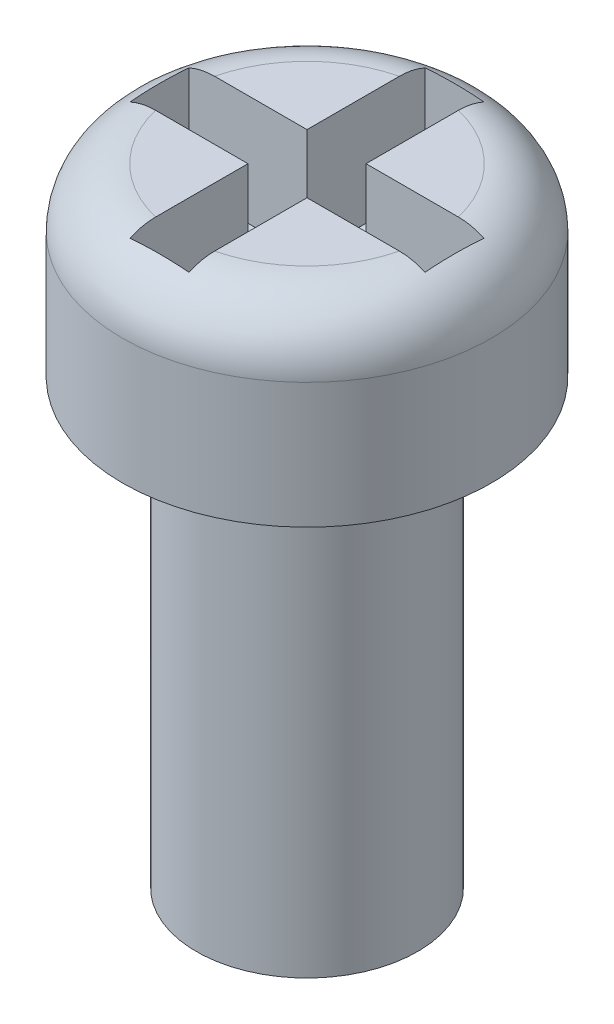
from build123d import *

# Parameters (mm, degrees)
REDONDEO1_R           = 0.8
CORTAR_EXTRUIR1_DEPTH = 1.5


with BuildPart() as part:
    # Croquis1 → Revolución1 (revolve)
    with BuildSketch(Plane.XY):
        Polygon((0, 0), (-1.5, 0), (-1.5, 6), (-2.5, 6), (-2.5, 8.5), (0, 8.5), align=None)
    revolve(axis=Axis((0, 0, 0), (0, 1, 0)))

    # Redondeo1
    redondeo1_edges = [part.edges().sort_by_distance(p)[0] for p in [
        (2.5, 8.5, 0),
    ]]
    fillet(redondeo1_edges, radius=REDONDEO1_R)

    # Croquis2 → Cortar-Extruir1 (cut)
    with BuildSketch(Plane(origin=(0, 8.5, 0), x_dir=(1, 0, 0), z_dir=(0, 1, 0))):
        Polygon((0.4, -2), (0.4, -0.4), (2, -0.4), (2, 0.4), (0.4, 0.4), (0.4, 2), (-0.4, 2), (-0.4, 0.4), (-2, 0.4), (-2, -0.4), (-0.4, -0.4), (-0.4, -2), align=None)
    extrude(amount=-CORTAR_EXTRUIR1_DEPTH, mode=Mode.SUBTRACT)


solid = part.part
